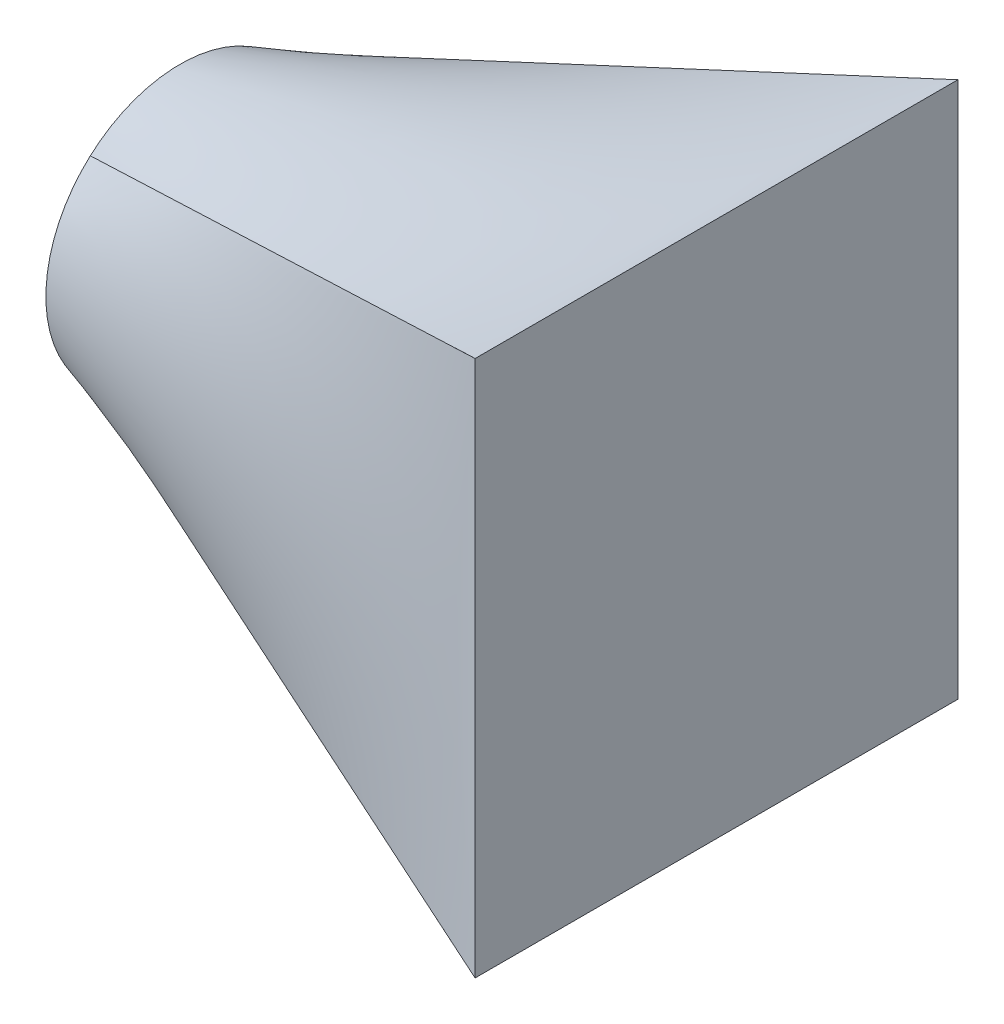
from build123d import *

# Parameters (mm, degrees)
SKICA2_W = 90
SKICA2_H = 100


with BuildPart() as part:
    # Skica1 for Spojit profi → Spojit profily1 section 0
    with BuildSketch(Plane(origin=(0, 0, 0), x_dir=(0, 0, -1), z_dir=(1, 0, 0))):
        with BuildLine():
            # circular arc as an exact rational Bezier (weights 1, cos(half-angle), 1)
            Bezier((-16.724118291, 18.582353656), (0, 33.634060118), (16.724118291, 18.582353656), weights=[1, 0.743294146, 1])
            Bezier((16.724118291, 18.582353656), (37.371177907, 0), (16.724118291, -18.582353656), weights=[1, 0.668964732, 1])
            Bezier((16.724118291, -18.582353656), (0, -33.634060118), (-16.724118291, -18.582353656), weights=[1, 0.743294146, 1])
            Bezier((-16.724118291, -18.582353656), (-37.371177907, 0), (-16.724118291, 18.582353656), weights=[1, 0.668964732, 1])
        make_face()
    # Skica2 → Spojit profily1 section 1
    with BuildSketch(Plane(origin=(100, 0, 0), x_dir=(0, 0, -1), z_dir=(1, 0, 0))):
        Rectangle(SKICA2_W, SKICA2_H)
    loft()


solid = part.part
